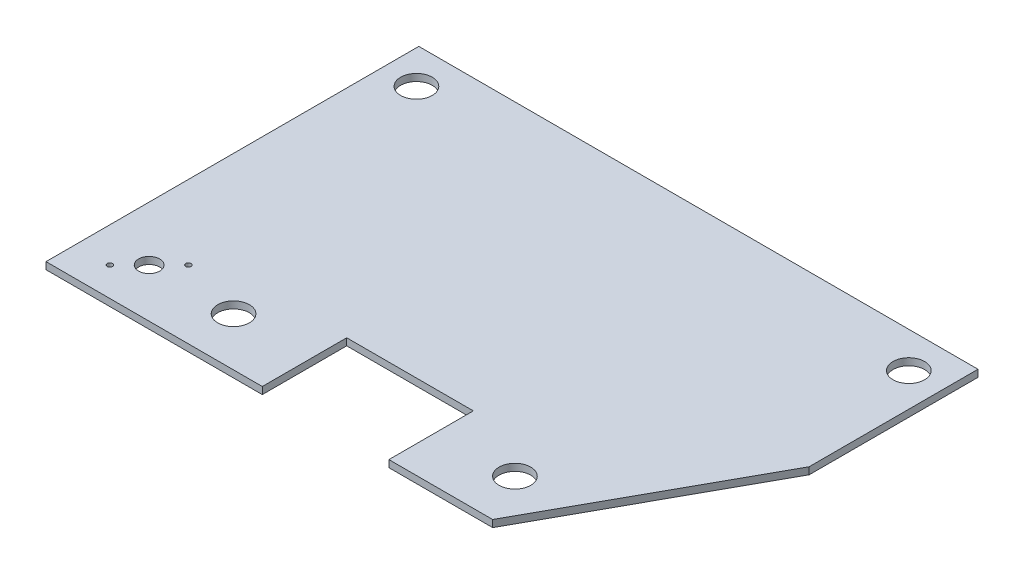
from build123d import *

# Parameters (mm, degrees)
SKETCH1_W               = 504.825
SKETCH1_H               = 336.55
BOSS_EXTRUDE1_DEPTH     = 3.175
SKETCH2_R               = 14.2748
CUT_EXTRUDE1_DEPTH      = 304.428522524
CUT_EXTRUDE3_DEPTH      = 304.428522524
SKETCH6_W               = 114.3
SKETCH6_H               = 76.2
CUT_EXTRUDE4_DEPTH      = 304.428522524
SKETCH8_R               = 2.413
SKETCH8_R_2             = 9.525
BOSS_EXTRUDE3_DEPTH     = 3.175
CUT_EXTRUDE5_DEPTH      = 304.378684825
CUT_EXTRUDE5_DEPTH_BACK = 304.378684825
SKETCH8_3_R             = 2.413


with BuildPart() as part:
    # Sketch1 → Boss-Extrude1 (new, symmetric)
    with BuildSketch(Plane(origin=(0, 0, 0), x_dir=(1, 0, 0), z_dir=(0, 1, 0))):
        Rectangle(SKETCH1_W, SKETCH1_H)
    extrude(amount=BOSS_EXTRUDE1_DEPTH, both=True)

    # Sketch2 → Cut-Extrude1 (cut, through all)
    with BuildSketch(Plane(origin=(0, 3.175, 0), x_dir=(1, 0, 0), z_dir=(0, 1, 0))):
        with Locations((-222.25, 135.975286336)):
            Circle(SKETCH2_R)
        with Locations((222.25, 135.975286336)):
            Circle(SKETCH2_R)
        with Locations((-127, -124.374713664)):
            Circle(SKETCH2_R)
        with Locations((127, -124.374713664)):
            Circle(SKETCH2_R)
    extrude(amount=-CUT_EXTRUDE1_DEPTH, mode=Mode.SUBTRACT)

    # Sketch5 → Cut-Extrude3 (cut, through all)
    with BuildSketch(Plane.XZ.offset(3.175)):
        Polygon((252.4125, 168.275), (252.4125, -15.875), (150.8125, 168.275), align=None)
        Polygon((-252.4125, -15.875), (-150.8125, 168.275), (-252.4125, 168.275), align=None)
    extrude(amount=-CUT_EXTRUDE3_DEPTH, mode=Mode.SUBTRACT)

    # Sketch6 → Cut-Extrude4 (cut, through all)
    with BuildSketch(Plane(origin=(0, 3.175, 0), x_dir=(1, 0, 0), z_dir=(0, 1, 0))):
        with Locations((0, -130.175)):
            Rectangle(SKETCH6_W, SKETCH6_H)
    extrude(amount=-CUT_EXTRUDE4_DEPTH, mode=Mode.SUBTRACT)

    # Sketch8 → Boss-Extrude3 (add, symmetric)
    with BuildSketch(Plane(origin=(0, 0, 0), x_dir=(1, 0, 0), z_dir=(0, 1, 0))):
        Polygon((-252.4125, 15.875), (-252.4125, -168.275), (-150.8125, -168.275), align=None)
        with Locations((-220.9292, -142.103913664)):
            Circle(SKETCH8_R, mode=Mode.SUBTRACT)
        with Locations((-203.2, -124.374713664)):
            Circle(SKETCH8_R_2, mode=Mode.SUBTRACT)
    extrude(amount=BOSS_EXTRUDE3_DEPTH, both=True)

    # Sketch8_3 → Cut-Extrude5 (cut, two sides: drawn at the far end of the back side and taken through both)
    with BuildSketch(Plane(origin=(0, 0, 0), x_dir=(1, 0, 0), z_dir=(0, 1, 0)).offset(-CUT_EXTRUDE5_DEPTH_BACK)):
        with Locations((-185.4708, -106.645513664)):
            Circle(SKETCH8_3_R)
    extrude(amount=CUT_EXTRUDE5_DEPTH + CUT_EXTRUDE5_DEPTH_BACK, mode=Mode.SUBTRACT)


solid = part.part
